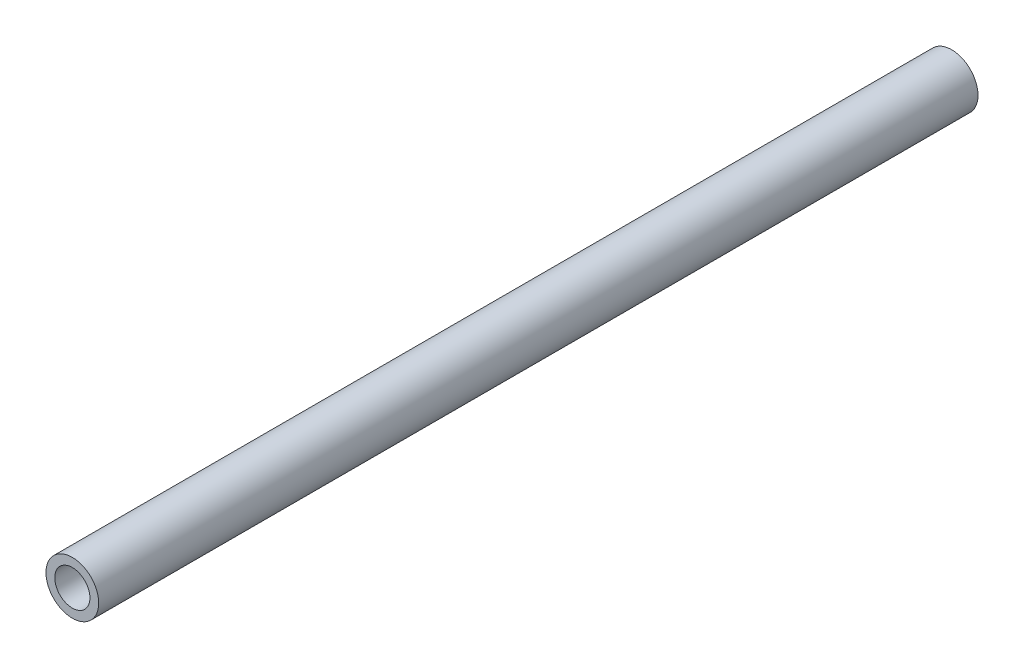
from build123d import *

# Parameters (mm, degrees)
SKETCH1_R                 = 3
BOSS_EXTRUDE1_DEPTH       = 50
F_4_0MM_DOWEL_HOLE1_D     = 4
F_4_0MM_DOWEL_HOLE1_DEPTH = 100


with BuildPart() as part:
    # Sketch1 → Boss-Extrude1 (new body, symmetric)
    with BuildSketch(Plane.XY):
        Circle(SKETCH1_R)
    extrude(amount=BOSS_EXTRUDE1_DEPTH, both=True)

    # Ø4.0mm Dowel Hole1
    with Locations(Plane.XY.offset(50)):
        with Locations((0, 0)):
            Hole(F_4_0MM_DOWEL_HOLE1_D / 2, depth=F_4_0MM_DOWEL_HOLE1_DEPTH)


solid = part.part
